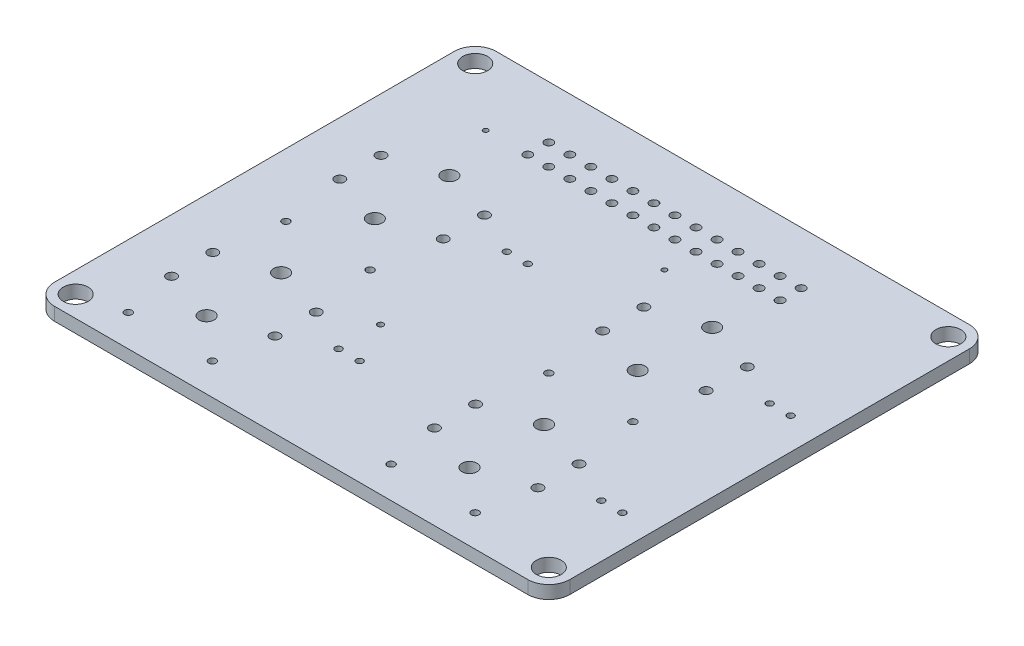
from build123d import *

# Parameters (mm, degrees)
BOSS_EXTRUDE1_DEPTH = 1.5748
SKETCH2_R           = 1.5
SKETCH2_R_2         = 0.3
SKETCH2_R_3         = 0.508
SKETCH2_R_4         = 0.5969
SKETCH2_R_5         = 0.449999989
SKETCH2_R_6         = 0.4064
SKETCH2_R_7         = 0.9017
SKETCH2_R_8         = 0.350000062
CUT_EXTRUDE1_DEPTH  = 2.5748


with BuildPart() as part:
    # Sketch1 → Boss-Extrude1 (new body)
    with BuildSketch(Plane(origin=(0, 0, 0), x_dir=(1, 0, 0), z_dir=(0, 1, 0))):
        with BuildLine():
            Line((-28.575, 26.67), (28.575, 26.67))
            ThreePointArc((28.575, 26.67), (30.371051224, 25.926051224), (31.115, 24.13))
            Line((31.115, 24.13), (31.115, -24.13))
            ThreePointArc((31.115, -24.13), (30.371051224, -25.926051224), (28.575, -26.67))
            Line((28.575, -26.67), (-28.575, -26.67))
            ThreePointArc((-28.575, -26.67), (-30.371051224, -25.926051224), (-31.115, -24.13))
            Line((-31.115, -24.13), (-31.115, 24.13))
            ThreePointArc((-31.115, 24.13), (-30.371051224, 25.926051224), (-28.575, 26.67))
        make_face()
    extrude(amount=BOSS_EXTRUDE1_DEPTH)

    # Sketch2 → Cut-Extrude1 (cut, through all)
    with BuildSketch(Plane(origin=(0, 1.5748, 0), x_dir=(1, 0, 0), z_dir=(0, 1, 0))):
        with Locations((-28.575, 24.13)):
            Circle(SKETCH2_R)
        with Locations((28.575, 24.13)):
            Circle(SKETCH2_R)
        with Locations((28.575, -24.13)):
            Circle(SKETCH2_R)
        with Locations((-28.575, -24.13)):
            Circle(SKETCH2_R)
        with Locations((-20.955, 17.78)):
            Circle(SKETCH2_R_2)
        with Locations((14.605, 20.32)):
            Circle(SKETCH2_R_3)
        with Locations((12.065, 20.32)):
            Circle(SKETCH2_R_3)
        with Locations((9.525, 20.32)):
            Circle(SKETCH2_R_3)
        with Locations((6.985, 20.32)):
            Circle(SKETCH2_R_3)
        with Locations((4.445, 20.32)):
            Circle(SKETCH2_R_3)
        with Locations((1.905, 20.32)):
            Circle(SKETCH2_R_3)
        with Locations((-0.635, 20.32)):
            Circle(SKETCH2_R_3)
        with Locations((-3.175, 20.32)):
            Circle(SKETCH2_R_3)
        with Locations((-5.715, 20.32)):
            Circle(SKETCH2_R_3)
        with Locations((-8.255, 20.32)):
            Circle(SKETCH2_R_3)
        with Locations((-10.795, 20.32)):
            Circle(SKETCH2_R_3)
        with Locations((-13.335, 20.32)):
            Circle(SKETCH2_R_3)
        with Locations((-15.875, 20.32)):
            Circle(SKETCH2_R_3)
        with Locations((12.065, 17.78)):
            Circle(SKETCH2_R_3)
        with Locations((9.525, 17.78)):
            Circle(SKETCH2_R_3)
        with Locations((6.985, 17.78)):
            Circle(SKETCH2_R_3)
        with Locations((4.445, 17.78)):
            Circle(SKETCH2_R_3)
        with Locations((1.905, 17.78)):
            Circle(SKETCH2_R_3)
        with Locations((-0.635, 17.78)):
            Circle(SKETCH2_R_3)
        with Locations((-3.175, 17.78)):
            Circle(SKETCH2_R_3)
        with Locations((-5.715, 17.78)):
            Circle(SKETCH2_R_3)
        with Locations((-8.255, 17.78)):
            Circle(SKETCH2_R_3)
        with Locations((-10.795, 17.78)):
            Circle(SKETCH2_R_3)
        with Locations((-13.335, 17.78)):
            Circle(SKETCH2_R_3)
        with Locations((-15.875, 17.78)):
            Circle(SKETCH2_R_3)
        with Locations((14.605, 17.78)):
            Circle(SKETCH2_R_3)
        with Locations((4.445, 13.97)):
            Circle(SKETCH2_R_2)
        with Locations((-24.6634, -11.4808)):
            Circle(SKETCH2_R_4)
        with Locations((-24.6634, -16.4592)):
            Circle(SKETCH2_R_4)
        with Locations((-12.1666, -16.4592)):
            Circle(SKETCH2_R_4)
        with Locations((-12.1666, -11.4808)):
            Circle(SKETCH2_R_4)
        with Locations((-23.495, -22.86)):
            Circle(SKETCH2_R_5)
        with Locations((-13.335, -22.86)):
            Circle(SKETCH2_R_5)
        with Locations((-6.985, -13.97)):
            Circle(SKETCH2_R_6)
        with Locations((-4.445, -13.97)):
            Circle(SKETCH2_R_6)
        with Locations((-18.415, -9.4742)):
            Circle(SKETCH2_R_7)
        with Locations((-18.415, -18.47)):
            Circle(SKETCH2_R_7)
        with Locations((7.0866, -11.4808)):
            Circle(SKETCH2_R_4)
        with Locations((7.0866, -16.4592)):
            Circle(SKETCH2_R_4)
        with Locations((19.5834, -16.4592)):
            Circle(SKETCH2_R_4)
        with Locations((19.5834, -11.4808)):
            Circle(SKETCH2_R_4)
        with Locations((24.765, -13.97)):
            Circle(SKETCH2_R_6)
        with Locations((27.305, -13.97)):
            Circle(SKETCH2_R_6)
        with Locations((13.335, -9.4742)):
            Circle(SKETCH2_R_7)
        with Locations((13.335, -18.47)):
            Circle(SKETCH2_R_7)
        with Locations((7.0866, 8.8392)):
            Circle(SKETCH2_R_4)
        with Locations((7.0866, 3.8608)):
            Circle(SKETCH2_R_4)
        with Locations((19.5834, 3.8608)):
            Circle(SKETCH2_R_4)
        with Locations((19.5834, 8.8392)):
            Circle(SKETCH2_R_4)
        with Locations((24.765, 6.35)):
            Circle(SKETCH2_R_6)
        with Locations((27.305, 6.35)):
            Circle(SKETCH2_R_6)
        with Locations((13.335, 10.8458)):
            Circle(SKETCH2_R_7)
        with Locations((13.335, 1.85)):
            Circle(SKETCH2_R_7)
        with Locations((-24.6634, 8.8392)):
            Circle(SKETCH2_R_4)
        with Locations((-24.6634, 3.8608)):
            Circle(SKETCH2_R_4)
        with Locations((-12.1666, 3.8608)):
            Circle(SKETCH2_R_4)
        with Locations((-12.1666, 8.8392)):
            Circle(SKETCH2_R_4)
        with Locations((-6.985, 6.35)):
            Circle(SKETCH2_R_6)
        with Locations((-4.445, 6.35)):
            Circle(SKETCH2_R_6)
        with Locations((-18.415, 10.8458)):
            Circle(SKETCH2_R_7)
        with Locations((-18.415, 1.85)):
            Circle(SKETCH2_R_7)
        with Locations((8.255, -22.86)):
            Circle(SKETCH2_R_5)
        with Locations((18.415, -22.86)):
            Circle(SKETCH2_R_5)
        with Locations((8.255, -3.81)):
            Circle(SKETCH2_R_5)
        with Locations((18.415, -3.81)):
            Circle(SKETCH2_R_5)
        with Locations((-23.495, -3.81)):
            Circle(SKETCH2_R_5)
        with Locations((-13.335, -3.81)):
            Circle(SKETCH2_R_5)
        with Locations((-6.985, -8.89)):
            Circle(SKETCH2_R_8)
    extrude(amount=-CUT_EXTRUDE1_DEPTH, mode=Mode.SUBTRACT)


solid = part.part
